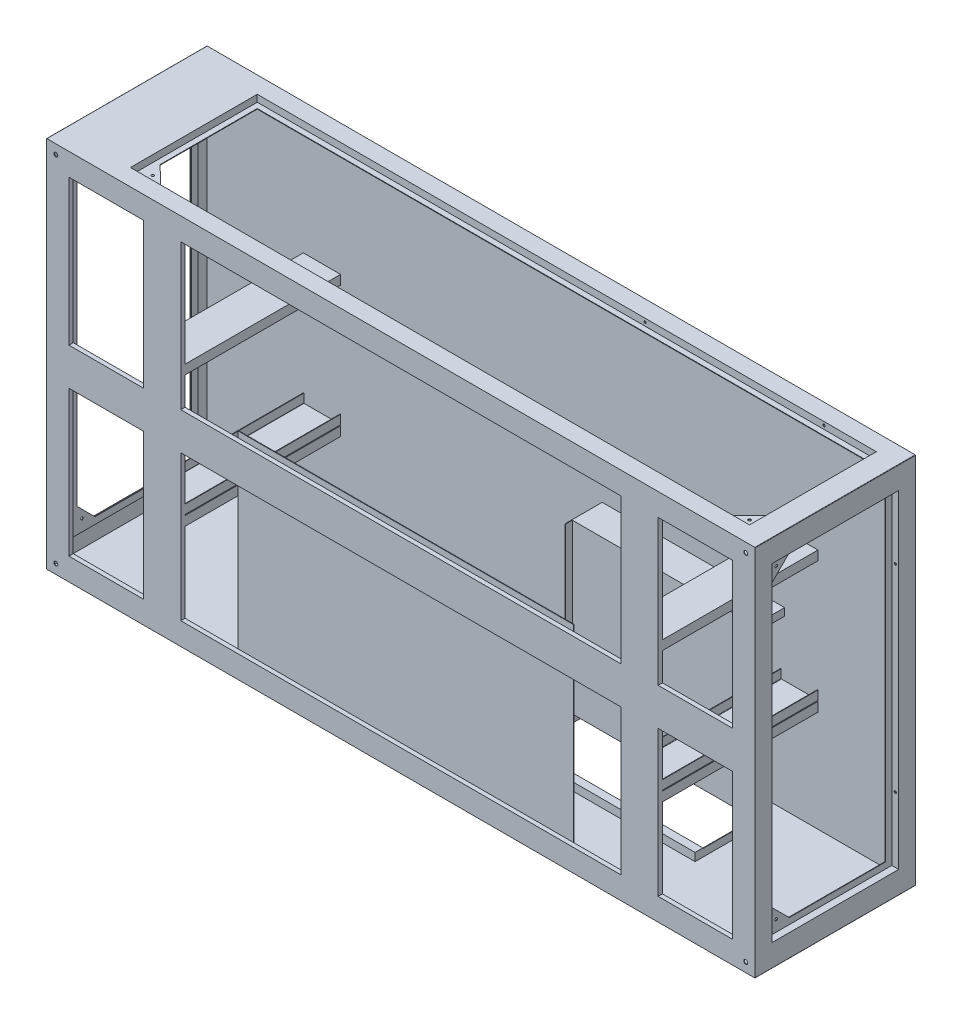
from build123d import *

# Parameters (mm, degrees)
SKETCH_1_W                     = 1900
SKETCH_1_H                     = 1000
SKETCH_1_W_2                   = 1897
SKETCH_1_H_2                   = 997
EXTRUDE_1_DEPTH                = 215
SKETCH_2_W                     = 1900
SKETCH_2_H                     = 1000
EXTRUDE_2_DEPTH                = 1.5
SKETCH_3_W                     = 340
SKETCH_3_H                     = 880
CUT_EXTRUDE_1_DEPTH            = 1.5
SKETCH_6_W                     = 1900
SKETCH_6_H                     = 1000
EXTRUDE_5_DEPTH                = 1.5
SKETCH_7_W                     = 200
SKETCH_7_H                     = 880
SKETCH_7_W_2                   = 1180
CUT_EXTRUDE_8_DEPTH            = 29.5
HOLE_WIZARD_10_5_10_5_1_D      = 10.5
HOLE_WIZARD_10_5_10_5_1_DEPTH  = 1.5
HOLE_WIZARD_10_5_10_5_1_TIP    = 3.15451825
SKETCH_10_W                    = 1660
SKETCH_10_H                    = 340
CUT_EXTRUDE_9_DEPTH            = 1.5
HOLE_WIZARD_25_5_25_5_1_D      = 25.5
HOLE_WIZARD_25_5_25_5_1_DEPTH  = 12
HOLE_WIZARD_25_5_25_5_1_TIP    = 7.660972893
FILLET_1_R                     = 1
SKETCH_17_W                    = 343
SKETCH_17_H                    = 883
SKETCH_17_W_2                  = 340
SKETCH_17_H_2                  = 880
EXTRUDE_8_DEPTH                = 17
SKETCH_18_W                    = 343
SKETCH_18_H                    = 883
SKETCH_18_W_2                  = 307
SKETCH_18_H_2                  = 847
EXTRUDE_9_DEPTH                = 1.5
SKETCH_19_W                    = 1663
SKETCH_19_H                    = 343
SKETCH_19_W_2                  = 1660
SKETCH_19_H_2                  = 340
EXTRUDE_10_DEPTH               = 17
SKETCH_20_W                    = 1663
SKETCH_20_H                    = 343
SKETCH_20_W_2                  = 1629.5
SKETCH_20_H_2                  = 309.5
EXTRUDE_11_DEPTH               = 1.5
EXTRUDE_18_REACH               = 430.5
SKETCH_34_W                    = 486
SKETCH_34_H                    = 180
CUT_EXTRUDE_13_DEPTH           = 1.5
SKETCH_35_W                    = 489
SKETCH_35_H                    = 183
SKETCH_35_W_2                  = 486
SKETCH_35_H_2                  = 180
EXTRUDE_19_DEPTH               = 20
EXTRUDE_20_DEPTH               = 450
EXTRUDE_21_REACH               = 430.5
SKETCH_38_W                    = 489
SKETCH_38_H                    = 23
EXTRUDE_22_DEPTH               = 1.5
SKETCH_39_W                    = 489
SKETCH_39_H                    = 21
EXTRUDE_23_DEPTH               = 1.5
EXTRUDE_24_DEPTH               = 1.5
EXTRUDE_25_DEPTH               = 1.5
HOLE_WIZARD_7_0_7_1_D          = 7
HOLE_WIZARD_7_0_7_1_DEPTH      = 1.5
HOLE_WIZARD_7_0_7_1_TIP        = 2.103012167
HOLE_WIZARD_4_6_4_6_2_D        = 7
HOLE_WIZARD_4_6_4_6_2_DEPTH    = 1.5
HOLE_WIZARD_4_6_4_6_2_TIP      = 2.103012167
SKETCH_47_R                    = 3.5
CUT_EXTRUDE_14_DEPTH           = 10
HOLE_WIZARD_6_0_6_1_D          = 6
HOLE_WIZARD_6_0_6_1_DEPTH      = 2
HOLE_WIZARD_6_0_6_1_TIP        = 1.802581857
HOLE_WIZARD_6_0_6_2_AT_2_COUNT = 2
HOLE_WIZARD_6_0_6_2_AT_2_PITCH = 530
SKETCH_52_W                    = 1.5
SKETCH_52_H                    = 100
EXTRUDE_26_DEPTH               = 1780
SKETCH_53_W                    = 203
SKETCH_53_H                    = 393
SKETCH_53_W_2                  = 200
SKETCH_53_H_2                  = 390
EXTRUDE_27_DEPTH               = 10
SKETCH_54_W                    = 1183
SKETCH_54_H                    = 393
SKETCH_54_W_2                  = 1180
SKETCH_54_H_2                  = 390
SKETCH_54_W_3                  = 203
SKETCH_54_W_4                  = 200
EXTRUDE_28_DEPTH               = 10
CHAMFER_1_SIZE                 = 2
SKETCH_58_W                    = 898.931133108
SKETCH_58_H                    = 565.983005072
EXTRUDE_31_DEPTH               = 1.5


with BuildPart() as part:
    # 草图1 → 凸台-拉伸1 (new body, symmetric)
    with BuildSketch(Plane.XY):
        Rectangle(SKETCH_1_W, SKETCH_1_H)
        Rectangle(SKETCH_1_W_2, SKETCH_1_H_2, mode=Mode.SUBTRACT)
    extrude(amount=EXTRUDE_1_DEPTH, both=True)

    # 草图2 → 凸台-拉伸2 (add)
    with BuildSketch(Plane(origin=(0, 0, -215), x_dir=(-1, 0, 0), z_dir=(0, 0, -1))):
        Rectangle(SKETCH_2_W, SKETCH_2_H)
    extrude(amount=-EXTRUDE_2_DEPTH)

    # 草图3 → 切除-拉伸1 (cut)
    with BuildSketch(Plane.ZY.offset(950)):
        Rectangle(SKETCH_3_W, SKETCH_3_H)
    cut_extrude_1 = extrude(amount=-CUT_EXTRUDE_1_DEPTH, mode=Mode.SUBTRACT)

    # 草图6 → 凸台-拉伸5 (add)
    with BuildSketch(Plane.XY.offset(215)):
        Rectangle(SKETCH_6_W, SKETCH_6_H)
    extrude(amount=-EXTRUDE_5_DEPTH)

    # 草图7 → 切除-拉伸8 (cut)
    with BuildSketch(Plane.XY.offset(227)):
        with Locations((-790, 0)):
            Rectangle(SKETCH_7_W, SKETCH_7_H)
        Rectangle(SKETCH_7_W_2, SKETCH_7_H)
        with Locations((790, 0)):
            Rectangle(SKETCH_7_W, SKETCH_7_H)
    extrude(amount=-CUT_EXTRUDE_8_DEPTH, mode=Mode.SUBTRACT)

    # Ø10.5 (10.5) 直径孔1
    with Locations(Plane.XY.offset(215)):
        with Locations((-925, 475), (925, 475), (-925, -475), (925, -475)):
            Hole(HOLE_WIZARD_10_5_10_5_1_D / 2, depth=HOLE_WIZARD_10_5_10_5_1_DEPTH)
            with Locations((0, 0, -(HOLE_WIZARD_10_5_10_5_1_DEPTH + HOLE_WIZARD_10_5_10_5_1_TIP / 2))):  # 118° drill point
                Cone(0, HOLE_WIZARD_10_5_10_5_1_D / 2, HOLE_WIZARD_10_5_10_5_1_TIP, mode=Mode.SUBTRACT)

    # 草图10 → 切除-拉伸9 (cut)
    with BuildSketch(Plane(origin=(0, 500, 0), x_dir=(1, 0, 0), z_dir=(0, 1, 0))):
        with Locations((60, 0)):
            Rectangle(SKETCH_10_W, SKETCH_10_H)
    extrude(amount=-CUT_EXTRUDE_9_DEPTH, mode=Mode.SUBTRACT)

    # Ø25.5 (25.5) 直径孔1
    with Locations(Plane(origin=(0, 0, -215), x_dir=(-1, 0, 0), z_dir=(0, 0, -1))):
        with Locations((-900, 450), (-900, -450), (900, -450), (900, 450)):
            Hole(HOLE_WIZARD_25_5_25_5_1_D / 2, depth=HOLE_WIZARD_25_5_25_5_1_DEPTH)
            with Locations((0, 0, -(HOLE_WIZARD_25_5_25_5_1_DEPTH + HOLE_WIZARD_25_5_25_5_1_TIP / 2))):  # 118° drill point
                Cone(0, HOLE_WIZARD_25_5_25_5_1_D / 2, HOLE_WIZARD_25_5_25_5_1_TIP, mode=Mode.SUBTRACT)

    # 圆角1
    fillet_1_edges = [part.edges().sort_by_distance(p)[0] for p in [
        (-950, 500, 0),
        (950, 500, 0),
        (950, -500, 0),
        (-950, -500, 0),
    ]]
    fillet(fillet_1_edges, radius=FILLET_1_R)

    # 草图17 → 凸台-拉伸8 (add)
    with BuildSketch(Plane(origin=(-948.5, 0, 0), x_dir=(0, 0, -1), z_dir=(1, 0, 0))):
        Rectangle(SKETCH_17_W, SKETCH_17_H)
        Rectangle(SKETCH_17_W_2, SKETCH_17_H_2, mode=Mode.SUBTRACT)
    extrude_8 = extrude(amount=EXTRUDE_8_DEPTH)

    # 草图18 → 凸台-拉伸9 (add)
    with BuildSketch(Plane(origin=(-931.5, 0, 0), x_dir=(0, 0, -1), z_dir=(1, 0, 0))):
        Rectangle(SKETCH_18_W, SKETCH_18_H)
        Rectangle(SKETCH_18_W_2, SKETCH_18_H_2, mode=Mode.SUBTRACT)
    extrude_9 = extrude(amount=EXTRUDE_9_DEPTH)

    # 镜向5: 切除-拉伸1 across plane
    add(cut_extrude_1.mirror(Plane(origin=(0, 0, 0), x_dir=(0, 0, 1), z_dir=(1, 0, 0))), mode=Mode.SUBTRACT)

    # 草图19 → 凸台-拉伸10 (add)
    with BuildSketch(Plane.XZ.offset(-498.5)):
        with Locations((60, 0)):
            Rectangle(SKETCH_19_W, SKETCH_19_H)
        with Locations((60, 0)):
            Rectangle(SKETCH_19_W_2, SKETCH_19_H_2, mode=Mode.SUBTRACT)
    extrude(amount=EXTRUDE_10_DEPTH)

    # 草图20 → 凸台-拉伸11 (add)
    with BuildSketch(Plane.XZ.offset(-481.5)):
        with Locations((60, 0)):
            Rectangle(SKETCH_20_W, SKETCH_20_H)
        with Locations((59.25, -0.75)):
            Rectangle(SKETCH_20_W_2, SKETCH_20_H_2, mode=Mode.SUBTRACT)
    extrude(amount=EXTRUDE_11_DEPTH)

    # 镜向6: 切除-拉伸1, 凸台-拉伸8, 凸台-拉伸9 across plane
    add(cut_extrude_1.mirror(Plane(origin=(0, 0, 0), x_dir=(0, 0, 1), z_dir=(1, 0, 0))), mode=Mode.SUBTRACT)
    add(extrude_8.mirror(Plane(origin=(0, 0, 0), x_dir=(0, 0, 1), z_dir=(1, 0, 0))))
    add(extrude_9.mirror(Plane(origin=(0, 0, 0), x_dir=(0, 0, 1), z_dir=(1, 0, 0))))

    # 草图33 → 凸台-拉伸18 (add, up to next)
    with BuildSketch(Plane(origin=(0, 0, 213.5), x_dir=(-1, 0, 0), z_dir=(0, 0, -1)), mode=Mode.PRIVATE) as extrude_18_sk1:
        with BuildLine():
            Line((-689, -200), (-591, -200))
            ThreePointArc((-591, -200), (-590.292893219, -199.707106781), (-590, -199))
            Line((-590, -199), (-590, -175))
            Line((-590, -175), (-591.5, -175))
            Line((-591.5, -175), (-591.5, -197.5))
            ThreePointArc((-591.5, -197.5), (-591.792893219, -198.207106781), (-592.5, -198.5))
            Line((-592.5, -198.5), (-687.5, -198.5))
            ThreePointArc((-687.5, -198.5), (-688.207106781, -198.207106781), (-688.5, -197.5))
            Line((-688.5, -197.5), (-688.5, -175))
            Line((-688.5, -175), (-690, -175))
            Line((-690, -175), (-690, -199))
            ThreePointArc((-690, -199), (-689.707106781, -199.707106781), (-689, -200))
        make_face()
    extrude_18_tool1 = extrude(extrude_18_sk1.sketch, amount=EXTRUDE_18_REACH, mode=Mode.PRIVATE) - part.part
    add(extrude_18_tool1.solids().sort_by_distance((640, -198.969224, 213.5))[0])
    # 草图33 → 凸台-拉伸18 (add, up to next)
    with BuildSketch(Plane(origin=(0, 0, 213.5), x_dir=(-1, 0, 0), z_dir=(0, 0, -1)), mode=Mode.PRIVATE) as extrude_18_sk2:
        with BuildLine():
            Line((590, -175), (591.5, -175))
            Line((591.5, -175), (591.5, -198))
            ThreePointArc((591.5, -198), (591.646446609, -198.353553391), (592, -198.5))
            Line((592, -198.5), (688, -198.5))
            ThreePointArc((688, -198.5), (688.353553391, -198.353553391), (688.5, -198))
            Line((688.5, -198), (688.5, -175))
            Line((688.5, -175), (690, -175))
            Line((690, -175), (690, -199))
            ThreePointArc((690, -199), (689.707106781, -199.707106781), (689, -200))
            Line((689, -200), (591, -200))
            ThreePointArc((591, -200), (590.292893219, -199.707106781), (590, -199))
            Line((590, -199), (590, -175))
        make_face()
    extrude_18_tool2 = extrude(extrude_18_sk2.sketch, amount=EXTRUDE_18_REACH, mode=Mode.PRIVATE) - part.part
    add(extrude_18_tool2.solids().sort_by_distance((-640, -198.969224, 213.5))[0])
    # 草图33 → 凸台-拉伸18 (add, up to next)
    with BuildSketch(Plane(origin=(0, 0, 213.5), x_dir=(-1, 0, 0), z_dir=(0, 0, -1)), mode=Mode.PRIVATE) as extrude_18_sk3:
        Polygon((-690, 125), (-690, 150), (-590, 150), (-590, 125), (-591.5, 125), (-591.5, 148.5), (-688.5, 148.5), (-688.5, 125), align=None)
    extrude_18_tool3 = extrude(extrude_18_sk3.sketch, amount=EXTRUDE_18_REACH, mode=Mode.PRIVATE) - part.part
    add(extrude_18_tool3.solids().sort_by_distance((688.969224, 137.5, 213.5))[0])
    # 草图33 → 凸台-拉伸18 (add, up to next)
    with BuildSketch(Plane(origin=(0, 0, 213.5), x_dir=(-1, 0, 0), z_dir=(0, 0, -1)), mode=Mode.PRIVATE) as extrude_18_sk4:
        Polygon((590, 125), (590, 150), (690, 150), (690, 125), (688.5, 125), (688.5, 148.5), (591.5, 148.5), (591.5, 125), align=None)
    extrude_18_tool4 = extrude(extrude_18_sk4.sketch, amount=EXTRUDE_18_REACH, mode=Mode.PRIVATE) - part.part
    add(extrude_18_tool4.solids().sort_by_distance((-591.030776, 137.5, 213.5))[0])
    # 草图33 → 凸台-拉伸18 (add, up to next)
    with BuildSketch(Plane(origin=(0, 0, 213.5), x_dir=(-1, 0, 0), z_dir=(0, 0, -1)), mode=Mode.PRIVATE) as extrude_18_sk5:
        Polygon((-690, -226.5), (-690, -201.5), (-590, -201.5), (-590, -226.5), (-591.5, -226.5), (-591.5, -203), (-688.5, -203), (-688.5, -226.5), align=None)
    extrude_18_tool5 = extrude(extrude_18_sk5.sketch, amount=EXTRUDE_18_REACH, mode=Mode.PRIVATE) - part.part
    add(extrude_18_tool5.solids().sort_by_distance((688.969224, -214, 213.5))[0])
    # 草图33 → 凸台-拉伸18 (add, up to next)
    with BuildSketch(Plane(origin=(0, 0, 213.5), x_dir=(-1, 0, 0), z_dir=(0, 0, -1)), mode=Mode.PRIVATE) as extrude_18_sk6:
        Polygon((590, -226.5), (590, -201.5), (690, -201.5), (690, -226.5), (688.5, -226.5), (688.5, -203), (591.5, -203), (591.5, -226.5), align=None)
    extrude_18_tool6 = extrude(extrude_18_sk6.sketch, amount=EXTRUDE_18_REACH, mode=Mode.PRIVATE) - part.part
    add(extrude_18_tool6.solids().sort_by_distance((-591.030776, -214, 213.5))[0])

    # 草图34 → 切除-拉伸13 (cut)
    with BuildSketch(Plane(origin=(0, -500, 0), x_dir=(-1, 0, 0), z_dir=(0, -1, 0))):
        with Locations((-356, 65)):
            Rectangle(SKETCH_34_W, SKETCH_34_H)
    extrude(amount=-CUT_EXTRUDE_13_DEPTH, mode=Mode.SUBTRACT)

    # 草图35 → 凸台-拉伸19 (add)
    with BuildSketch(Plane(origin=(0, -498.5, 0), x_dir=(1, 0, 0), z_dir=(0, 1, 0))):
        with Locations((356, 65)):
            Rectangle(SKETCH_35_W, SKETCH_35_H)
        with Locations((356, 65)):
            Rectangle(SKETCH_35_W_2, SKETCH_35_H_2, mode=Mode.SUBTRACT)
    extrude(amount=EXTRUDE_19_DEPTH)

    # 草图36 → 凸台-拉伸20 (add)
    with BuildSketch(Plane(origin=(0, -478.5, 0), x_dir=(1, 0, 0), z_dir=(0, 1, 0))):
        Polygon((600.5, 113.5), (599, 113.5), (599, 132), (113, 132), (113, 113.5), (111.5, 113.5), (111.5, 133.5), (600.5, 133.5), align=None)
    extrude(amount=EXTRUDE_20_DEPTH)

    # 草图37 → 凸台-拉伸21 (add, up to next)
    with BuildSketch(Plane.XY.offset(-213.5), mode=Mode.PRIVATE) as extrude_21_sk1:
        Polygon((600.5, -48.5), (600.5, -28.5), (111.5, -28.5), (111.5, -48.5), (113, -48.5), (113, -30), (599, -30), (599, -48.5), align=None)
    extrude_21_tool1 = extrude(extrude_21_sk1.sketch, amount=EXTRUDE_21_REACH, mode=Mode.PRIVATE) - part.part
    add(extrude_21_tool1.solids().sort_by_distance((356, -29.953422, -213.5))[0])

    # 草图38 → 凸台-拉伸22 (add)
    with BuildSketch(Plane(origin=(0, -478.5, 0), x_dir=(1, 0, 0), z_dir=(0, 1, 0))):
        with Locations((356, 145)):
            Rectangle(SKETCH_38_W, SKETCH_38_H)
    extrude(amount=EXTRUDE_22_DEPTH)

    # 草图39 → 凸台-拉伸23 (add)
    with BuildSketch(Plane(origin=(0, -478.5, 0), x_dir=(1, 0, 0), z_dir=(0, 1, 0))):
        with Locations((356, -16)):
            Rectangle(SKETCH_39_W, SKETCH_39_H)
    extrude(amount=EXTRUDE_23_DEPTH)

    # 草图41 → 凸台-拉伸24 (add)
    with BuildSketch(Plane.ZY.offset(931.5)):
        Polygon((153.5, 423.5), (153.5, 375), (105, 423.5), align=None)
        Polygon((153.5, -375), (153.5, -423.5), (105, -423.5), align=None)
    extrude_24 = extrude(amount=-EXTRUDE_24_DEPTH)

    # 镜向7: 凸台-拉伸24 across plane
    add(extrude_24.mirror(Plane(origin=(0, 0, 0), x_dir=(0, 0, 1), z_dir=(1, 0, 0))))

    # 草图42 → 凸台-拉伸25 (add)
    with BuildSketch(Plane(origin=(0, 481.5, 0), x_dir=(1, 0, 0), z_dir=(0, 1, 0))):
        Polygon((874, -154), (825, -154), (874, -105), align=None)
        Polygon((-755.5, -154), (-705, -154), (-755.5, -105), align=None)
    extrude(amount=-EXTRUDE_25_DEPTH)

    # Ø7.0 (7) 直径孔1
    with Locations(Plane(origin=(0, 481.5, 0), x_dir=(1, 0, 0), z_dir=(0, 1, 0))):
        with Locations((-740, -140), (860, -140)):
            Hole(HOLE_WIZARD_7_0_7_1_D / 2, depth=HOLE_WIZARD_7_0_7_1_DEPTH)
            with Locations((0, 0, -(HOLE_WIZARD_7_0_7_1_DEPTH + HOLE_WIZARD_7_0_7_1_TIP / 2))):  # 118° drill point
                Cone(0, HOLE_WIZARD_7_0_7_1_D / 2, HOLE_WIZARD_7_0_7_1_TIP, mode=Mode.SUBTRACT)

    # Ø4.6 (4.6) 直径孔2
    with Locations(Plane(origin=(931.5, 0, 0), x_dir=(0, 0, -1), z_dir=(1, 0, 0))):
        with Locations((-140, -410), (-140, 410)):
            Hole(HOLE_WIZARD_4_6_4_6_2_D / 2, depth=HOLE_WIZARD_4_6_4_6_2_DEPTH)
            with Locations((0, 0, -(HOLE_WIZARD_4_6_4_6_2_DEPTH + HOLE_WIZARD_4_6_4_6_2_TIP / 2))):  # 118° drill point
                Cone(0, HOLE_WIZARD_4_6_4_6_2_D / 2, HOLE_WIZARD_4_6_4_6_2_TIP, mode=Mode.SUBTRACT)

    # 草图47 → 切除-拉伸14 (cut)
    with BuildSketch(Plane.ZY.offset(931.5)):
        with Locations((140, -410)):
            Circle(SKETCH_47_R)
        with Locations((140, 410)):
            Circle(SKETCH_47_R)
    extrude(amount=-CUT_EXTRUDE_14_DEPTH, mode=Mode.SUBTRACT)

    # Ø6.0 (6) 直径孔1
    with Locations(Plane.XY.offset(-170)):
        with Locations((750, 491), (270, 491)):
            Hole(HOLE_WIZARD_6_0_6_1_D / 2, depth=HOLE_WIZARD_6_0_6_1_DEPTH)
            with Locations((0, 0, -(HOLE_WIZARD_6_0_6_1_DEPTH + HOLE_WIZARD_6_0_6_1_TIP / 2))):  # 118° drill point
                Cone(0, HOLE_WIZARD_6_0_6_1_D / 2, HOLE_WIZARD_6_0_6_1_TIP, mode=Mode.SUBTRACT)

    # 草图50 → Ø6.0 (6) 直径孔2 (revolve, cut)
    with BuildSketch(Plane(origin=(941, -265, -170), x_dir=(0, -1, 0), z_dir=(1, 0, 0))):
        Polygon((0, 0), (0, 3.802581857), (3, 2), (3, 0), align=None)
    hole_wizard_6_0_6_2 = revolve(axis=Axis((941, -265, -163.65), (0, 0, -1)), mode=Mode.SUBTRACT)

    # Ø6.0 (6) 直径孔2 at 2: Ø6.0 (6) 直径孔2 ×2
    with Locations(*[(0, i * HOLE_WIZARD_6_0_6_2_AT_2_PITCH, 0) for i in range(1, HOLE_WIZARD_6_0_6_2_AT_2_COUNT)]):
        add(hole_wizard_6_0_6_2, mode=Mode.SUBTRACT)

    # 镜向8: Ø6.0 (6) 直径孔2 across plane
    add(hole_wizard_6_0_6_2.mirror(Plane(origin=(0, 0, 0), x_dir=(0, 0, 1), z_dir=(1, 0, 0))), mode=Mode.SUBTRACT)

    # 镜向8 copy 1 sketch → 镜向8 copy 1 (revolve, cut)
    with BuildSketch(Plane(origin=(-941, 265, -170), x_dir=(0, -1, 0), z_dir=(-1, 0, 0))):
        Polygon((0, 0), (0, -3.802581857), (3, -2), (3, 0), align=None)
    revolve(axis=Axis((-941, 265, -163.65), (0, 0, 1)), mode=Mode.SUBTRACT)

    # 草图52 → 凸台-拉伸26 (add)
    with BuildSketch(Plane.ZY.offset(-890)):
        with Locations((214.25, 0)):
            Rectangle(SKETCH_52_W, SKETCH_52_H)
    extrude(amount=EXTRUDE_26_DEPTH)

    # 草图53 → 凸台-拉伸27 (add)
    with BuildSketch(Plane(origin=(0, 0, 213.5), x_dir=(-1, 0, 0), z_dir=(0, 0, -1))):
        with Locations((-790, -245)):
            Rectangle(SKETCH_53_W, SKETCH_53_H)
        with Locations((-790, -245)):
            Rectangle(SKETCH_53_W_2, SKETCH_53_H_2, mode=Mode.SUBTRACT)
        with Locations((-790, 245)):
            Rectangle(SKETCH_53_W, SKETCH_53_H)
        with Locations((-790, 245)):
            Rectangle(SKETCH_53_W_2, SKETCH_53_H_2, mode=Mode.SUBTRACT)
    extrude(amount=EXTRUDE_27_DEPTH)

    # 草图54 → 凸台-拉伸28 (add)
    with BuildSketch(Plane(origin=(0, 0, 213.5), x_dir=(-1, 0, 0), z_dir=(0, 0, -1))):
        with Locations((0, -245)):
            Rectangle(SKETCH_54_W, SKETCH_54_H)
        with Locations((0, -245)):
            Rectangle(SKETCH_54_W_2, SKETCH_54_H_2, mode=Mode.SUBTRACT)
        with Locations((0, 245)):
            Rectangle(SKETCH_54_W, SKETCH_54_H)
        with Locations((0, 245)):
            Rectangle(SKETCH_54_W_2, SKETCH_54_H_2, mode=Mode.SUBTRACT)
        with Locations((790, 245)):
            Rectangle(SKETCH_54_W_3, SKETCH_54_H)
        with Locations((790, 245)):
            Rectangle(SKETCH_54_W_4, SKETCH_54_H_2, mode=Mode.SUBTRACT)
        with Locations((790, -245)):
            Rectangle(SKETCH_54_W_3, SKETCH_54_H)
        with Locations((790, -245)):
            Rectangle(SKETCH_54_W_4, SKETCH_54_H_2, mode=Mode.SUBTRACT)
    extrude(amount=EXTRUDE_28_DEPTH)

    # 倒角1
    chamfer_1_edges = [part.edges().sort_by_distance(p)[0] for p in [
        (112.25, -28.5, -113.5),
        (599.75, -28.5, -113.5),
    ]]
    chamfer(chamfer_1_edges, length=CHAMFER_1_SIZE)

    # 草图58 → 凸台-拉伸31 (add)
    with BuildSketch(Plane(origin=(0, 0, 203.5), x_dir=(-1, 0, 0), z_dir=(0, 0, -1))):
        with Locations((-1.548599033, -217.008497464)):
            Rectangle(SKETCH_58_W, SKETCH_58_H)
    extrude(amount=EXTRUDE_31_DEPTH)


solid = part.part
